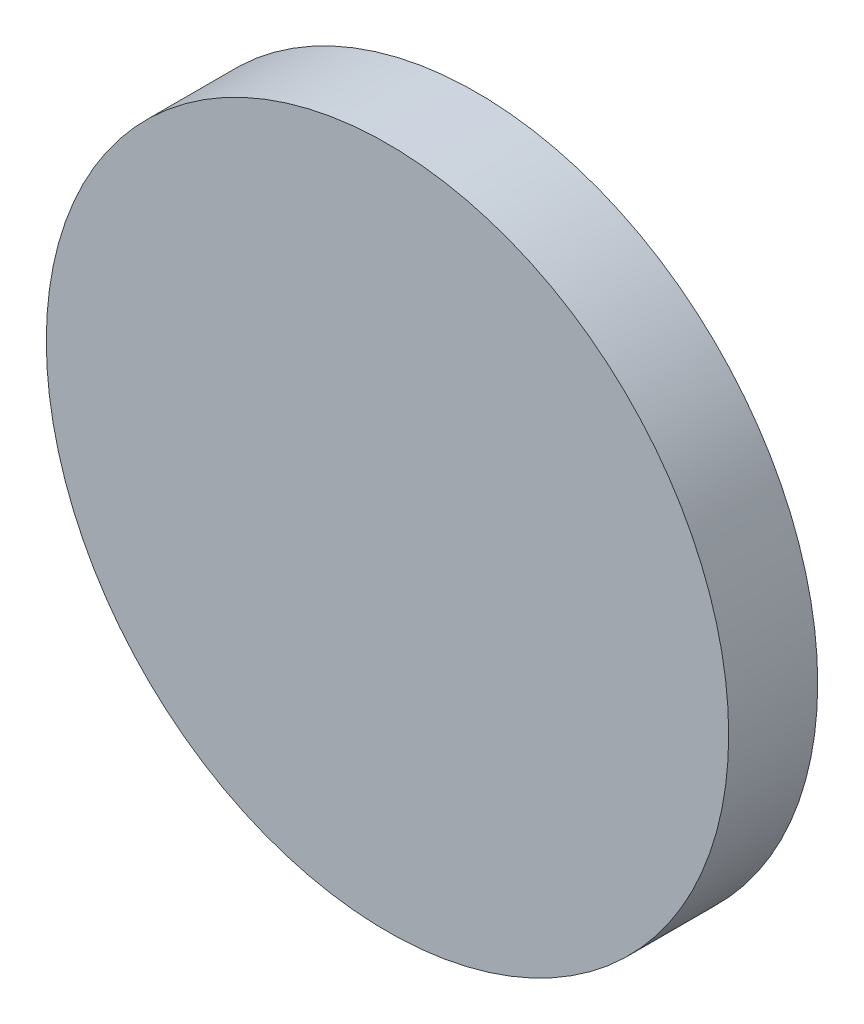
from build123d import *

# Parameters (mm, degrees)
SKETCH1_R           = 11.5
BOSS_EXTRUDE1_DEPTH = 3


with BuildPart() as part:
    # Sketch1 → Boss-Extrude1 (new body)
    with BuildSketch(Plane.XY):
        Circle(SKETCH1_R)
    extrude(amount=BOSS_EXTRUDE1_DEPTH)


solid = part.part
